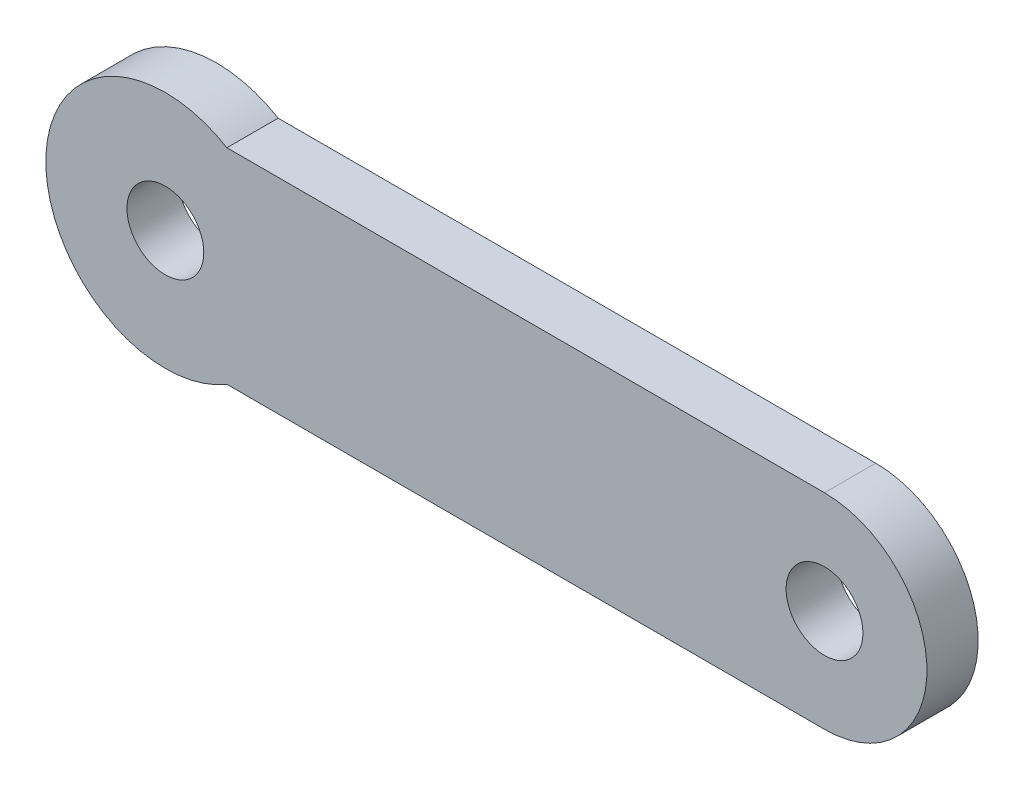
from build123d import *

# Parameters (mm, degrees)
SKETCH1_R           = 2.25
BOSS_EXTRUDE1_DEPTH = 3


with BuildPart() as part:
    # Sketch1 → Boss-Extrude1 (new body)
    with BuildSketch(Plane.XY):
        with BuildLine():
            Line((3.605551275, 6), (38.605551275, 6))
            ThreePointArc((38.605551275, 6), (44.605551275, 0), (38.605551275, -6))
            Line((38.605551275, -6), (3.605551275, -6))
            ThreePointArc((3.605551275, -6), (-7, 0), (3.605551275, 6))
        make_face()
        Circle(SKETCH1_R, mode=Mode.SUBTRACT)
        with Locations((38.605551275, 0)):
            Circle(SKETCH1_R, mode=Mode.SUBTRACT)
    extrude(amount=BOSS_EXTRUDE1_DEPTH)


solid = part.part
